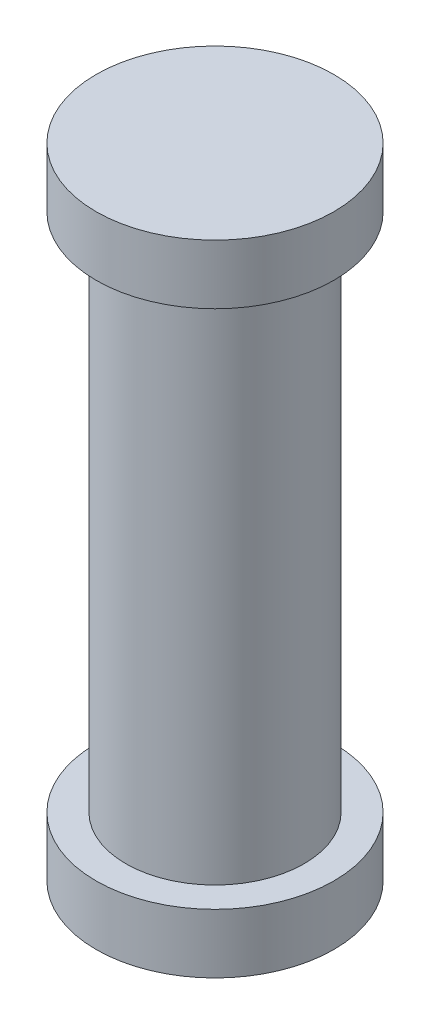
from build123d import *

# Parameters (mm, degrees)
SKETCH1_R           = 1.6
BOSS_EXTRUDE1_DEPTH = 0.8
SKETCH2_R           = 1.2
BOSS_EXTRUDE2_DEPTH = 7
SKETCH3_R           = 1.6
BOSS_EXTRUDE3_DEPTH = 0.8


with BuildPart() as part:
    # Sketch1 → Boss-Extrude1 (new body)
    with BuildSketch(Plane(origin=(0, 0, 0), x_dir=(1, 0, 0), z_dir=(0, 1, 0))):
        Circle(SKETCH1_R)
    extrude(amount=BOSS_EXTRUDE1_DEPTH)

    # Sketch2 → Boss-Extrude2 (add)
    with BuildSketch(Plane(origin=(0, 0.8, 0), x_dir=(1, 0, 0), z_dir=(0, 1, 0))):
        Circle(SKETCH2_R)
    extrude(amount=BOSS_EXTRUDE2_DEPTH)

    # Sketch3 → Boss-Extrude3 (add)
    with BuildSketch(Plane(origin=(0, 7.8, 0), x_dir=(1, 0, 0), z_dir=(0, 1, 0))):
        Circle(SKETCH3_R)
    extrude(amount=BOSS_EXTRUDE3_DEPTH)


solid = part.part
